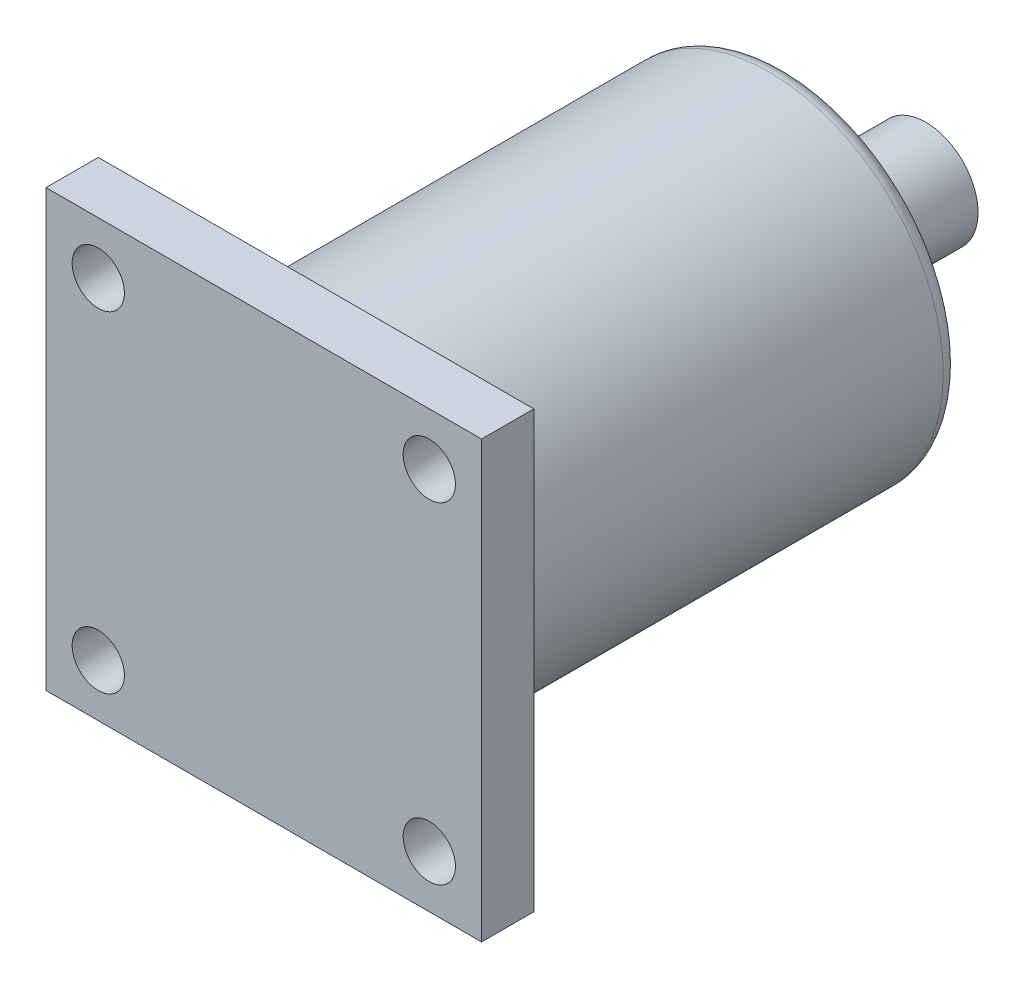
from build123d import *

# Parameters (mm, degrees)
SKETCH_2_W          = 25
SKETCH_2_H          = 25
EXTRUDE_1_DEPTH     = 3
SKETCH_3_R          = 1.5
CUT_EXTRUDE_2_DEPTH = 4
EXTRUDE_START       = -3
SKETCH_4_R          = 10
EXTRUDE_2_DEPTH     = 27
SKETCH_5_R          = 3
EXTRUDE_3_DEPTH     = 8
FILLET_3_R          = 1


with BuildPart() as part:
    # 草图2 → 凸台-拉伸1 (new body)
    with BuildSketch(Plane.XY):
        with Locations((12.5, -12.5)):
            Rectangle(SKETCH_2_W, SKETCH_2_H)
    extrude(amount=EXTRUDE_1_DEPTH)

    # 草图3 → 切除-拉伸2 (cut, through all)
    with BuildSketch(Plane(origin=(0, 0, 0), x_dir=(-1, 0, 0), z_dir=(0, 0, -1))):
        with Locations((-22, -3)):
            Circle(SKETCH_3_R)
        with Locations((-3, -3)):
            Circle(SKETCH_3_R)
        with Locations((-3, -22)):
            Circle(SKETCH_3_R)
        with Locations((-22, -22)):
            Circle(SKETCH_3_R)
    extrude(amount=-CUT_EXTRUDE_2_DEPTH, mode=Mode.SUBTRACT)

    # 草图4 → 凸台-拉伸2 (add)
    with BuildSketch(Plane.XY.offset(3).offset(EXTRUDE_START)):
        with Locations((12.5, -12.5)):
            Circle(SKETCH_4_R)
    extrude(amount=-EXTRUDE_2_DEPTH)

    # 草图5 → 凸台-拉伸3 (add)
    with BuildSketch(Plane(origin=(0, 0, -27), x_dir=(-1, 0, 0), z_dir=(0, 0, -1))):
        with Locations((-12.5, -12.5)):
            Circle(SKETCH_5_R)
    extrude(amount=EXTRUDE_3_DEPTH)

    # 圆角3
    fillet_3_edges = [part.edges().sort_by_distance(p)[0] for p in [
        (2.5, -12.5, -27),
        (2.5, -12.5, 0),
    ]]
    fillet(fillet_3_edges, radius=FILLET_3_R)


solid = part.part
